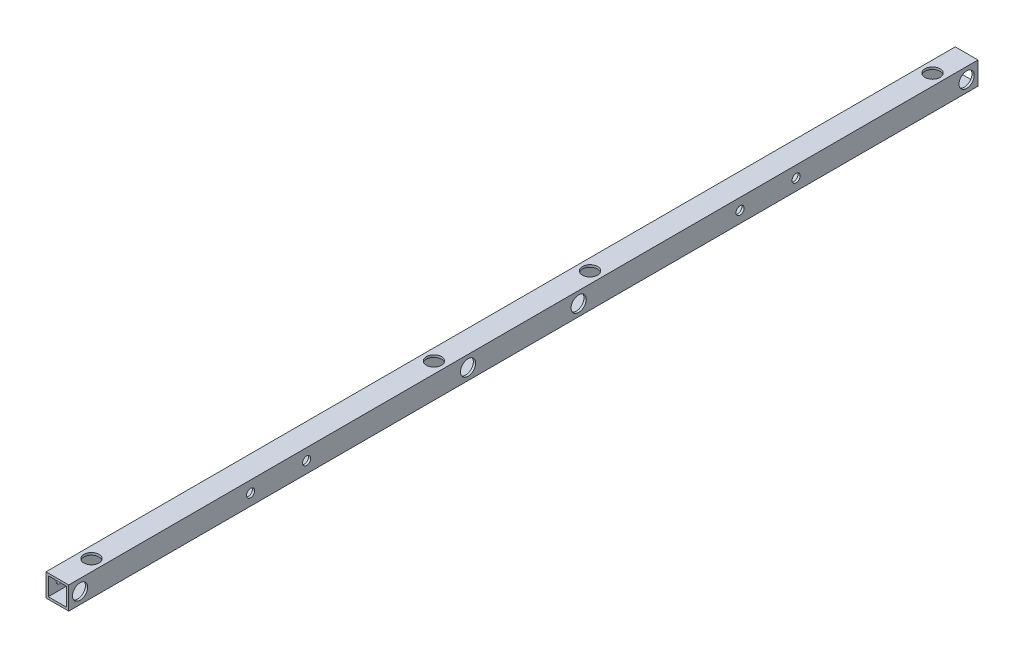
from build123d import *

# Parameters (mm, degrees)
SKETCH_1_W          = 15
SKETCH_1_H          = 15
SKETCH_1_W_2        = 12
SKETCH_1_H_2        = 12
EXTRUDE_1_DEPTH     = 600
SKETCH_2_R          = 2.25
CUT_EXTRUDE_1_DEPTH = 25
SKETCH_3_R          = 2.25
CUT_EXTRUDE_2_DEPTH = 25
SKETCH_4_R          = 5
CUT_EXTRUDE_3_DEPTH = 10
SKETCH_5_R          = 5
CUT_EXTRUDE_4_DEPTH = 10
SKETCH_6_R          = 2.7
CUT_EXTRUDE_5_DEPTH = 20
SKETCH_7_R          = 5
CUT_EXTRUDE_6_DEPTH = 3


with BuildPart() as part:
    # ｽｹｯﾁ1 → ﾎﾞｽ - 押し出し1 (new body)
    with BuildSketch(Plane.XY):
        Rectangle(SKETCH_1_W, SKETCH_1_H)
        Rectangle(SKETCH_1_W_2, SKETCH_1_H_2, mode=Mode.SUBTRACT)
    extrude(amount=EXTRUDE_1_DEPTH)

    # ｽｹｯﾁ2 → ｶｯﾄ - 押し出し1 (cut)
    with BuildSketch(Plane(origin=(7.5, 0, 0), x_dir=(0, 0, -1), z_dir=(1, 0, 0))):
        with Locations((-592.5, 0)):
            Circle(SKETCH_2_R)
        with Locations((-7.5, 0)):
            Circle(SKETCH_2_R)
        with Locations((-336.5, 0)):
            Circle(SKETCH_2_R)
        with Locations((-263.5, 0)):
            Circle(SKETCH_2_R)
    extrude(amount=-CUT_EXTRUDE_1_DEPTH, mode=Mode.SUBTRACT)

    # ｽｹｯﾁ3 → ｶｯﾄ - 押し出し2 (cut)
    with BuildSketch(Plane(origin=(0, 7.5, 0), x_dir=(1, 0, 0), z_dir=(0, 1, 0))):
        with Locations((0, -22.5)):
            Circle(SKETCH_3_R)
        with Locations((0, -577.5)):
            Circle(SKETCH_3_R)
        with Locations((0, -351.5)):
            Circle(SKETCH_3_R)
        with Locations((0, -248.5)):
            Circle(SKETCH_3_R)
    extrude(amount=-CUT_EXTRUDE_2_DEPTH, mode=Mode.SUBTRACT)

    # ｽｹｯﾁ4 → ｶｯﾄ - 押し出し3 (cut)
    with BuildSketch(Plane(origin=(0, 7.5, 0), x_dir=(1, 0, 0), z_dir=(0, 1, 0))):
        with Locations((0, -577.5)):
            Circle(SKETCH_4_R)
        with Locations((0, -351.5)):
            Circle(SKETCH_4_R)
        with Locations((0, -248.5)):
            Circle(SKETCH_4_R)
        with Locations((0, -22.5)):
            Circle(SKETCH_4_R)
    extrude(amount=-CUT_EXTRUDE_3_DEPTH, mode=Mode.SUBTRACT)

    # ｽｹｯﾁ5 → ｶｯﾄ - 押し出し4 (cut)
    with BuildSketch(Plane(origin=(7.5, 0, 0), x_dir=(0, 0, -1), z_dir=(1, 0, 0))):
        with Locations((-592.5, 0)):
            Circle(SKETCH_5_R)
        with Locations((-336.5, 0)):
            Circle(SKETCH_5_R)
        with Locations((-263.5, 0)):
            Circle(SKETCH_5_R)
        with Locations((-7.5, 0)):
            Circle(SKETCH_5_R)
    extrude(amount=-CUT_EXTRUDE_4_DEPTH, mode=Mode.SUBTRACT)

    # ｽｹｯﾁ6 → ｶｯﾄ - 押し出し5 (cut)
    with BuildSketch(Plane(origin=(7.5, 0, 0), x_dir=(0, 0, -1), z_dir=(1, 0, 0))):
        with Locations((-480, 0)):
            Circle(SKETCH_6_R)
        with Locations((-443, 0)):
            Circle(SKETCH_6_R)
        with Locations((-157, 0)):
            Circle(SKETCH_6_R)
        with Locations((-120, 0)):
            Circle(SKETCH_6_R)
    extrude(amount=-CUT_EXTRUDE_5_DEPTH, mode=Mode.SUBTRACT)

    # ｽｹｯﾁ7 → ｶｯﾄ - 押し出し6 (cut)
    with BuildSketch(Plane.ZY.offset(7.5)):
        with Locations((120, 0)):
            Circle(SKETCH_7_R)
        with Locations((157, 0)):
            Circle(SKETCH_7_R)
        with Locations((443, 0)):
            Circle(SKETCH_7_R)
        with Locations((480, 0)):
            Circle(SKETCH_7_R)
    extrude(amount=-CUT_EXTRUDE_6_DEPTH, mode=Mode.SUBTRACT)


solid = part.part
